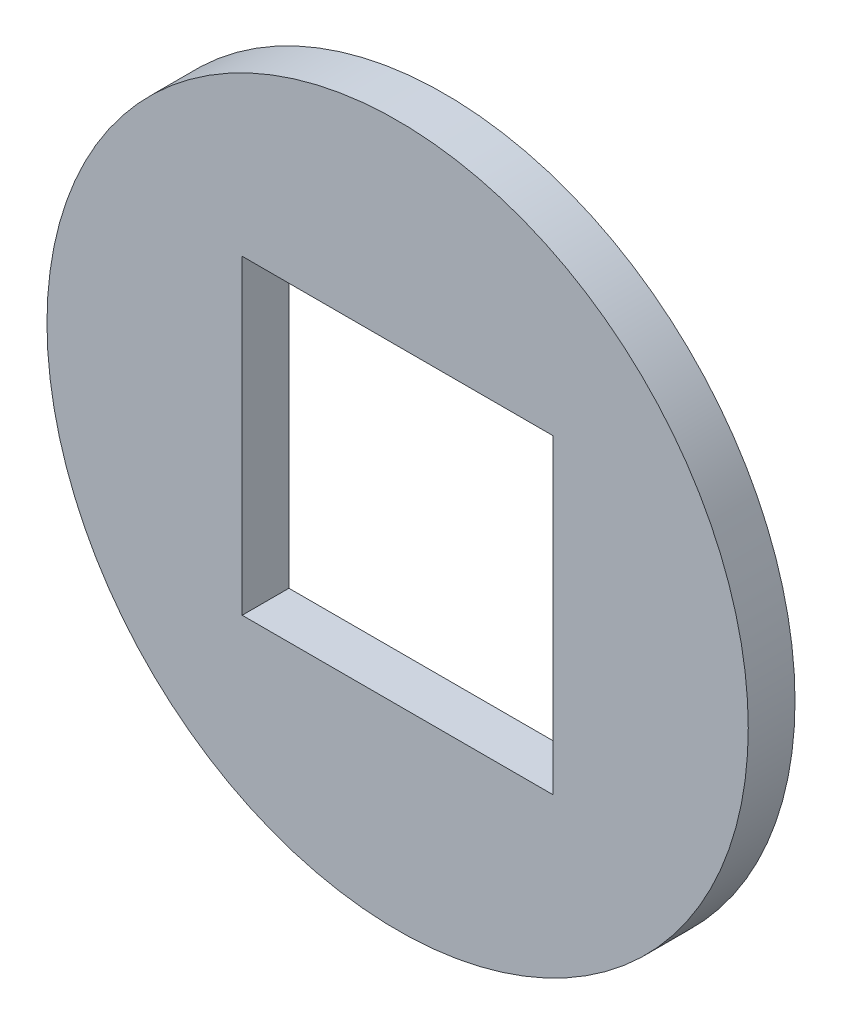
from build123d import *

# Parameters (mm, degrees)
SKETCH1_R           = 7.5
SKETCH1_W           = 6.65
SKETCH1_H           = 6.65
BOSS_EXTRUDE1_DEPTH = 0.5


with BuildPart() as part:
    # Sketch1 → Boss-Extrude1 (new, symmetric)
    with BuildSketch(Plane.XY):
        Circle(SKETCH1_R)
        Rectangle(SKETCH1_W, SKETCH1_H, mode=Mode.SUBTRACT)
    extrude(amount=BOSS_EXTRUDE1_DEPTH, both=True)


solid = part.part
